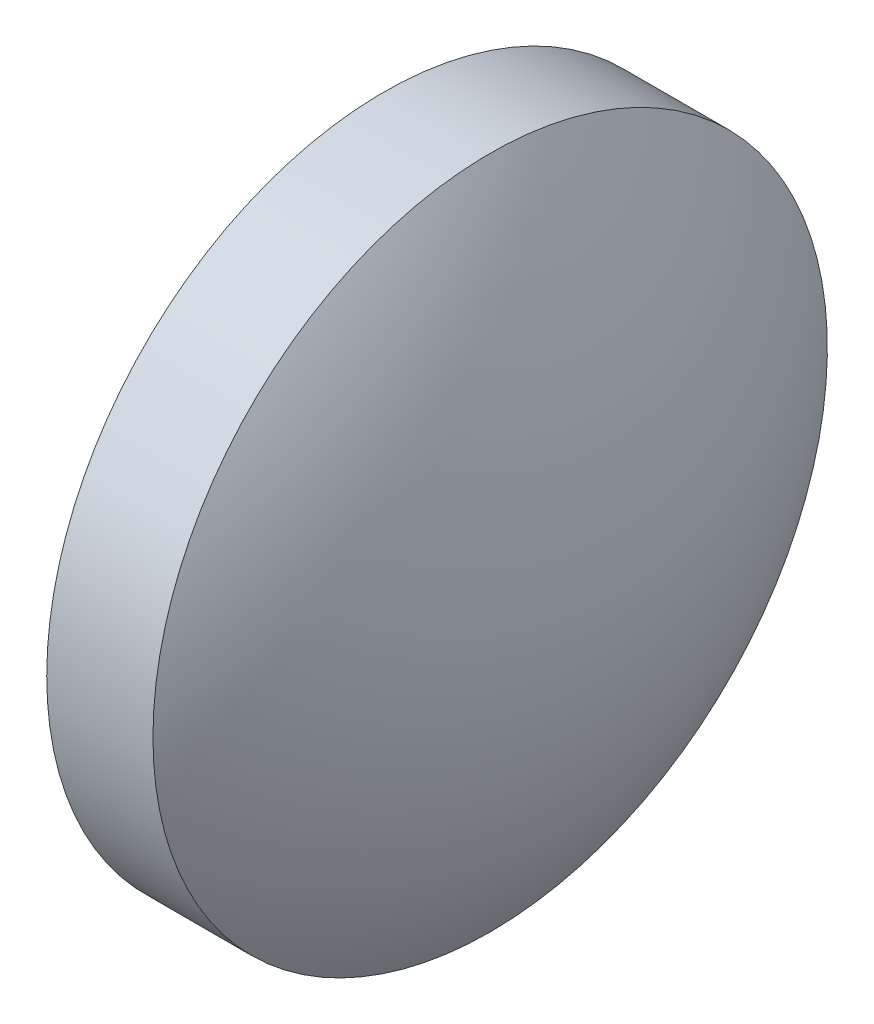
from build123d import *


with BuildPart() as part:
    # 草图1 → 旋转1 (revolve)
    with BuildSketch(Plane.XY, mode=Mode.PRIVATE) as revolve_1_sk:
        with BuildLine():
            Line((352.469835081, -36.860451207), (352.469835081, -30.510451207))
            Line((352.469835081, -30.510451207), (354.469835081, -30.510451207))
            ThreePointArc((354.469835081, -30.510451207), (355.899338883, -33.543491002), (356.389835081, -36.860451207))
            Line((356.389835081, -36.860451207), (352.469835081, -36.860451207))
        make_face()
    revolve(revolve_1_sk.sketch.rotate(Axis((350.141806591, -36.860451207, 0), (1, 0, 0)), 180), axis=Axis((350.141806591, -36.860451207, 0), (1, 0, 0)))  # turned: the seam where the file's is


solid = part.part
